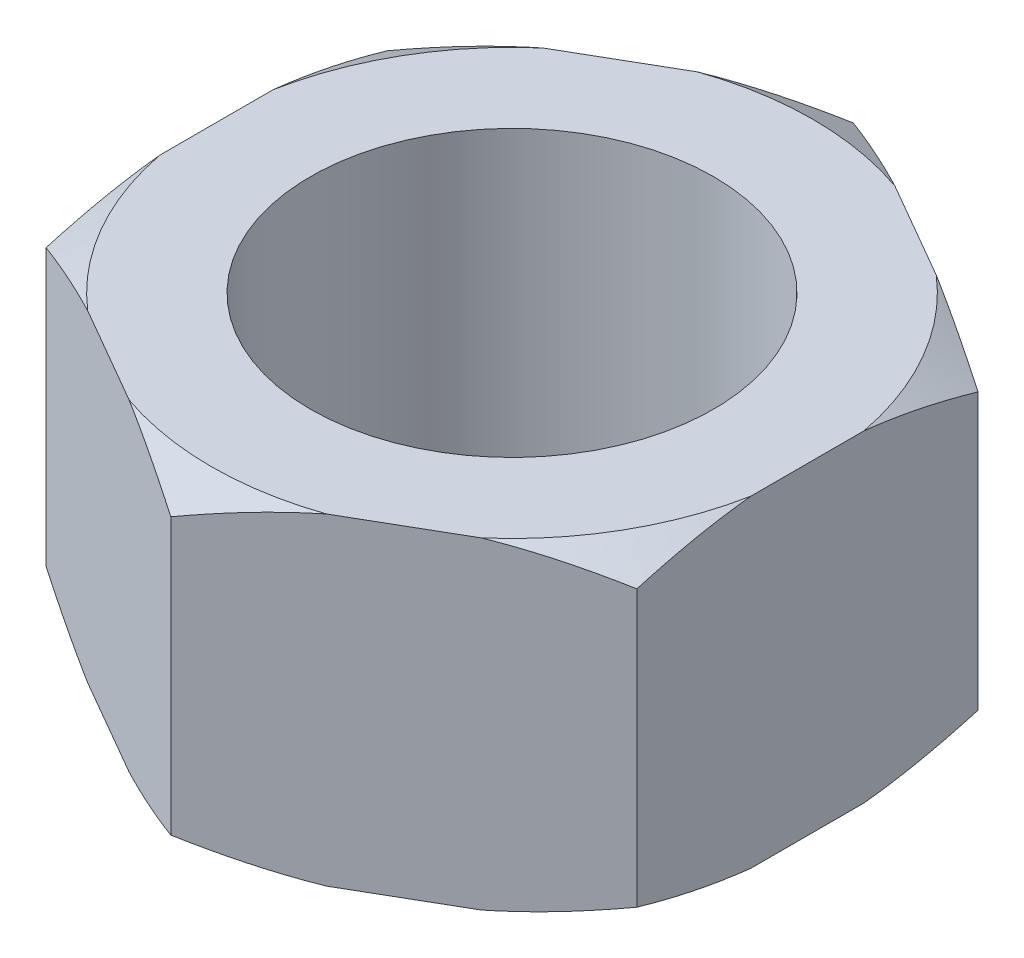
from build123d import *

# Parameters (mm, degrees)
BOSS_EXTRUDE1_DEPTH = 9.525
SKETCH4_W           = 11.9126
SKETCH4_H           = 19.05
SKETCH9_R           = 14.605
SKETCH9_R_2         = 13.335
BOSS_EXTRUDE2_DEPTH = 1.27


with BuildPart() as part:
    # Sketch1 → Boss-Extrude1 (new body, symmetric)
    with BuildSketch(Plane(origin=(0, 0, 0), x_dir=(1, 0, 0), z_dir=(0, 1, 0))):
        Polygon((17.4625, 10.081979076), (0, 20.163958151), (-17.4625, 10.081979076), (-17.4625, -10.081979076), (0, -20.163958151), (17.4625, -10.081979076), align=None)
    extrude(amount=BOSS_EXTRUDE1_DEPTH, both=True)

    # Sketch4 → Cut-Revolve1 (revolve, cut)
    with BuildSketch(Plane(origin=(0, 0, 0), x_dir=(0, 0, -1), z_dir=(1, 0, 0))):
        with Locations((-5.9563, 0)):
            Rectangle(SKETCH4_W, SKETCH4_H)
        Polygon((-17.78, -9.525), (-20.163958151, -8.14862112), (-20.163958151, -9.525), align=None)
        Polygon((-20.163958151, 9.525), (-17.78, 9.525), (-20.163958151, 8.14862112), align=None)
    revolve(axis=Axis((0, -9.525, 0), (0, 1, 0)), mode=Mode.SUBTRACT)

    # Sketch9 → Boss-Extrude2 (add)
    with BuildSketch(Plane.XZ.offset(9.525)):
        Circle(SKETCH9_R)
        Circle(SKETCH9_R_2, mode=Mode.SUBTRACT)
    extrude(amount=BOSS_EXTRUDE2_DEPTH)


solid = part.part
